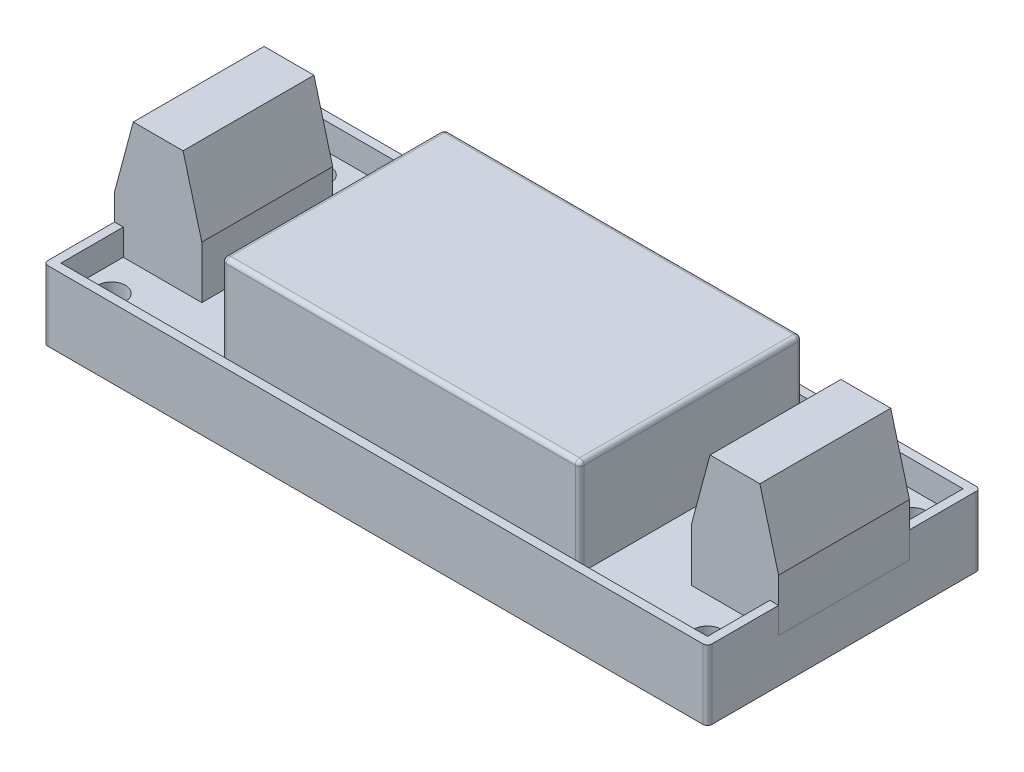
from build123d import *
from OCP.BRepFilletAPI import BRepFilletAPI_MakeChamfer

# Parameters (mm, degrees)
SKETCH1_W             = 76.1
SKETCH1_H             = 31.3
SKETCH1_R             = 1.6
BOSS_EXTRUDE1_DEPTH   = 5
BOSS_EXTRUDE2_DEPTH   = 3
SKETCH2_3_W           = 41
SKETCH2_3_H           = 25.5
BOSS_EXTRUDE3_DEPTH   = 11
SKETCH2_4_W           = 10
SKETCH2_4_H           = 15
BOSS_EXTRUDE4_DEPTH   = 14
BOSS_EXTRUDE4_2_DEPTH = 14
FILLET1_R             = 0.5
CHAMFER1_SIZE         = 8
CHAMFER1_SIZE2        = 2.143593539
CHAMFER2_SIZE         = 8
CHAMFER2_SIZE2        = 2.143593539


with BuildPart() as part:
    # Sketch1 → Boss-Extrude1 (new body)
    with BuildSketch(Plane(origin=(0, 0, 0), x_dir=(1, 0, 0), z_dir=(0, 1, 0))):
        Rectangle(SKETCH1_W, SKETCH1_H)
        with Locations((34.15, 11.75)):
            Circle(SKETCH1_R, mode=Mode.SUBTRACT)
        with Locations((34.15, -11.75)):
            Circle(SKETCH1_R, mode=Mode.SUBTRACT)
        with Locations((-34.15, -11.75)):
            Circle(SKETCH1_R, mode=Mode.SUBTRACT)
        with Locations((-34.15, 11.75)):
            Circle(SKETCH1_R, mode=Mode.SUBTRACT)
    extrude(amount=BOSS_EXTRUDE1_DEPTH)

    # Sketch2 → Boss-Extrude2 (add)
    with BuildSketch(Plane(origin=(0, 5, 0), x_dir=(1, 0, 0), z_dir=(0, 1, 0))):
        Polygon((-38.05, -15.65), (38.05, -15.65), (38.05, -7.5), (37.05, -7.5), (37.05, -14.65), (-37.05, -14.65), (-37.05, -7.5), (-38.05, -7.5), align=None)
        Polygon((37.05, 7.5), (38.05, 7.5), (38.05, 15.65), (-38.05, 15.65), (-38.05, 7.5), (-37.05, 7.5), (-37.05, 14.65), (37.05, 14.65), align=None)
    extrude(amount=BOSS_EXTRUDE2_DEPTH)

    # Sketch2_3 → Boss-Extrude3 (add)
    with BuildSketch(Plane(origin=(0, 5, 0), x_dir=(1, 0, 0), z_dir=(0, 1, 0))):
        Rectangle(SKETCH2_3_W, SKETCH2_3_H)
    extrude(amount=BOSS_EXTRUDE3_DEPTH)

    # Fillet1
    fillet1_edges = [part.edges().sort_by_distance(p)[0] for p in [
        (0, 16, -12.75),
        (-20.5, 16, 0),
        (0, 16, 12.75),
        (20.5, 16, 0),
        (20.5, 10.5, 12.75),
        (20.5, 10.5, -12.75),
        (-20.5, 10.5, -12.75),
        (-20.5, 10.5, 12.75),
        (-38.05, 4, 15.65),
        (-38.05, 4, -15.65),
        (38.05, 4, -15.65),
        (38.05, 4, 15.65),
    ]]
    fillet(fillet1_edges, radius=FILLET1_R)


with BuildPart() as body_2:
    # Sketch2_4 → Boss-Extrude4 (new body)
    with BuildSketch(Plane(origin=(0, 5, 0), x_dir=(1, 0, 0), z_dir=(0, 1, 0))):
        with Locations((33.05, 0)):
            Rectangle(SKETCH2_4_W, SKETCH2_4_H)
    extrude(amount=BOSS_EXTRUDE4_DEPTH)

    # Chamfer2: one chamfer whose edges measure the first distance from different faces: ONE call of the kernel's chamfer builder (chamfer() names one face for all edges)
    chamfer2_edges_1 = [body_2.edges().sort_by_distance(p)[0] for p in [
        (38.05, 19, 0),
    ]]
    chamfer2_side_1 = [body_2.faces().sort_by_distance(p)[0] for p in [
        (38.05, 12, 0),
    ]]
    chamfer2_edges_2 = [body_2.edges().sort_by_distance(p)[0] for p in [
        (28.05, 19, 0),
    ]]
    chamfer2_side_2 = [body_2.faces().sort_by_distance(p)[0] for p in [
        (28.05, 12, 0),
    ]]
    chamfer2 = BRepFilletAPI_MakeChamfer(body_2.part.solid().wrapped)
    for e in chamfer2_edges_1:
        chamfer2.Add(CHAMFER2_SIZE, CHAMFER2_SIZE2, e.wrapped, chamfer2_side_1[0].wrapped)  # the first distance lies on this face
    for e in chamfer2_edges_2:
        chamfer2.Add(CHAMFER2_SIZE, CHAMFER2_SIZE2, e.wrapped, chamfer2_side_2[0].wrapped)  # the first distance lies on this face
    add(Compound.cast(chamfer2.Shape()), mode=Mode.REPLACE)


with BuildPart() as body_3:
    # Sketch2_4 → Boss-Extrude4 2 (new body)
    with BuildSketch(Plane(origin=(0, 5, 0), x_dir=(1, 0, 0), z_dir=(0, 1, 0))):
        with Locations((-33.05, 0)):
            Rectangle(SKETCH2_4_W, SKETCH2_4_H)
    extrude(amount=BOSS_EXTRUDE4_2_DEPTH)

    # Chamfer1: one chamfer whose edges measure the first distance from different faces: ONE call of the kernel's chamfer builder (chamfer() names one face for all edges)
    chamfer1_edges_1 = [body_3.edges().sort_by_distance(p)[0] for p in [
        (-28.05, 19, 0),
    ]]
    chamfer1_side_1 = [body_3.faces().sort_by_distance(p)[0] for p in [
        (-28.05, 12, 0),
    ]]
    chamfer1_edges_2 = [body_3.edges().sort_by_distance(p)[0] for p in [
        (-38.05, 19, 0),
    ]]
    chamfer1_side_2 = [body_3.faces().sort_by_distance(p)[0] for p in [
        (-38.05, 12, 0),
    ]]
    chamfer1 = BRepFilletAPI_MakeChamfer(body_3.part.solid().wrapped)
    for e in chamfer1_edges_1:
        chamfer1.Add(CHAMFER1_SIZE, CHAMFER1_SIZE2, e.wrapped, chamfer1_side_1[0].wrapped)  # the first distance lies on this face
    for e in chamfer1_edges_2:
        chamfer1.Add(CHAMFER1_SIZE, CHAMFER1_SIZE2, e.wrapped, chamfer1_side_2[0].wrapped)  # the first distance lies on this face
    add(Compound.cast(chamfer1.Shape()), mode=Mode.REPLACE)


solid = Compound([part.part, body_2.part, body_3.part])
